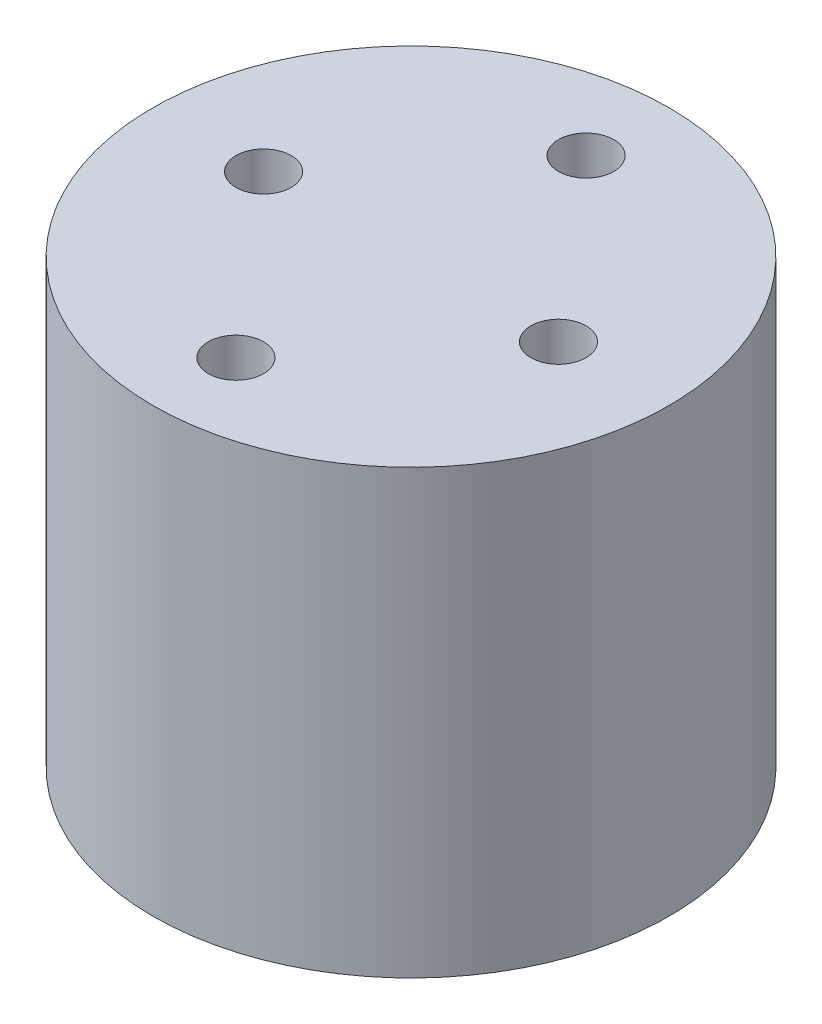
from build123d import *

# Parameters (mm, degrees)
SKETCH1_R           = 14
BOSS_EXTRUDE1_DEPTH = 24
SKETCH2_R           = 1.5
CUT_EXTRUDE1_DEPTH  = 3
SKETCH3_R           = 4
BOSS_EXTRUDE2_DEPTH = 2


with BuildPart() as part:
    # Sketch1 → Boss-Extrude1 (new body)
    with BuildSketch(Plane(origin=(0, 0, 0), x_dir=(1, 0, 0), z_dir=(0, 1, 0))):
        Circle(SKETCH1_R)
    extrude(amount=BOSS_EXTRUDE1_DEPTH)

    # Sketch2 → Cut-Extrude1 (cut)
    with BuildSketch(Plane(origin=(0, 24, 0), x_dir=(1, 0, 0), z_dir=(0, 1, 0))):
        with Locations((8, 0)):
            Circle(SKETCH2_R)
        with Locations((0, 9.5)):
            Circle(SKETCH2_R)
        with Locations((-8, 0)):
            Circle(SKETCH2_R)
        with Locations((0, -9.5)):
            Circle(SKETCH2_R)
    extrude(amount=-CUT_EXTRUDE1_DEPTH, mode=Mode.SUBTRACT)

    # Sketch3 → Boss-Extrude2 (add)
    with BuildSketch(Plane.XZ):
        Circle(SKETCH3_R)
    extrude(amount=BOSS_EXTRUDE2_DEPTH)


solid = part.part
